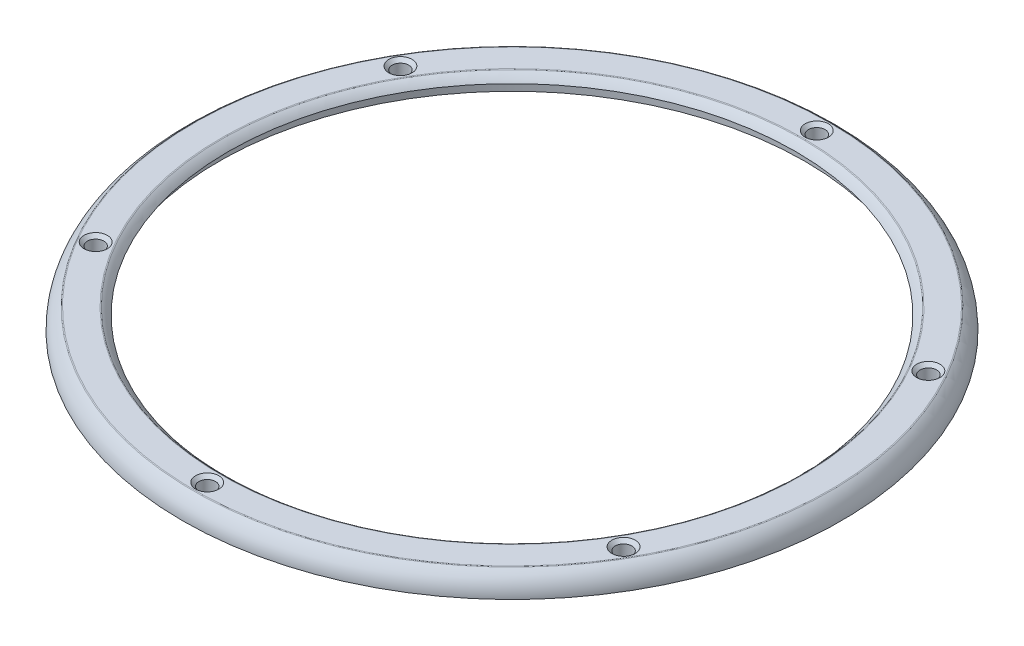
from build123d import *

# Parameters (mm, degrees)
ESQUISSE3_R                               = 0.5
ENL_V_MAT_EXTRU_1_DEPTH                   = 2.25
CHANFREIN1_SIZE                           = 0.2
R_P_TITION_CIRCULAIRE1_COUNT              = 6
CHANFREIN1_OF_R_P_TITION_CIRCULAIRE1_SIZE = 0.2
CONG_1_R                                  = 0.1


with BuildPart() as part:
    # Esquisse1 → Révolution1 (revolve)
    with BuildSketch(Plane(origin=(0, 0, 0), x_dir=(0, 0, -1), z_dir=(1, 0, 0))):
        with BuildLine():
            Line((-17.62, 0), (-19.82, 0))
            ThreePointArc((-19.82, 0), (-19.641691018, 0.709318583), (-19.149156198, 1.25))
            Line((-19.149156198, 1.25), (-17.490843802, 1.25))
            ThreePointArc((-17.490843802, 1.25), (-17.247134382, 1.048312627), (-17.051142246, 0.8))
            Line((-17.051142246, 0.8), (-17.62, 0.8))
            Line((-17.62, 0.8), (-17.62, 0))
        make_face()
    revolve(axis=Axis((0, 0, 0), (0, 1, 0)))

    # Esquisse3 → Enlèv. mat.-Extru.1 (cut, through all)
    with BuildSketch(Plane(origin=(0, 0, 0), x_dir=(1, 0, 0), z_dir=(0, 1, 0))):
        with Locations((0, 18.33)):
            Circle(ESQUISSE3_R)
    enl_v_mat_extru_1 = extrude(amount=ENL_V_MAT_EXTRU_1_DEPTH, mode=Mode.SUBTRACT)

    # Chanfrein1
    chanfrein1_edges = [part.edges().sort_by_distance(p)[0] for p in [
        (-0.5, 1.25, -18.33),
    ]]
    chamfer(chanfrein1_edges, length=CHANFREIN1_SIZE)

    # Répétition circulaire1: Enlèv. mat.-Extru.1 ×6 about axis
    r_p_tition_circulaire1_axis = Axis((0, 0, 0), (0, 1, 0))
    for i in range(1, R_P_TITION_CIRCULAIRE1_COUNT):
        add(enl_v_mat_extru_1.rotate(r_p_tition_circulaire1_axis, i * 360 / R_P_TITION_CIRCULAIRE1_COUNT), mode=Mode.SUBTRACT)

    # Chanfrein1 of Répétition circulaire1
    chanfrein1_of_r_p_tition_circulaire1_edges = [part.edges().sort_by_distance(p)[0] for p in [
        (-16.124245651, 1.25, -8.731987298),
        (-15.624245651, 1.25, 9.598012702),
        (0.5, 1.25, 18.33),
        (16.124245651, 1.25, 8.731987298),
        (15.624245651, 1.25, -9.598012702),
    ]]
    chamfer(chanfrein1_of_r_p_tition_circulaire1_edges, length=CHANFREIN1_OF_R_P_TITION_CIRCULAIRE1_SIZE)

    # Congé1
    cong_1_edges = [part.edges().sort_by_distance(p)[0] for p in [
        (0, 1.25, -19.149156198),
        (0, 1.25, -17.490843802),
    ]]
    fillet(cong_1_edges, radius=CONG_1_R)


solid = part.part
